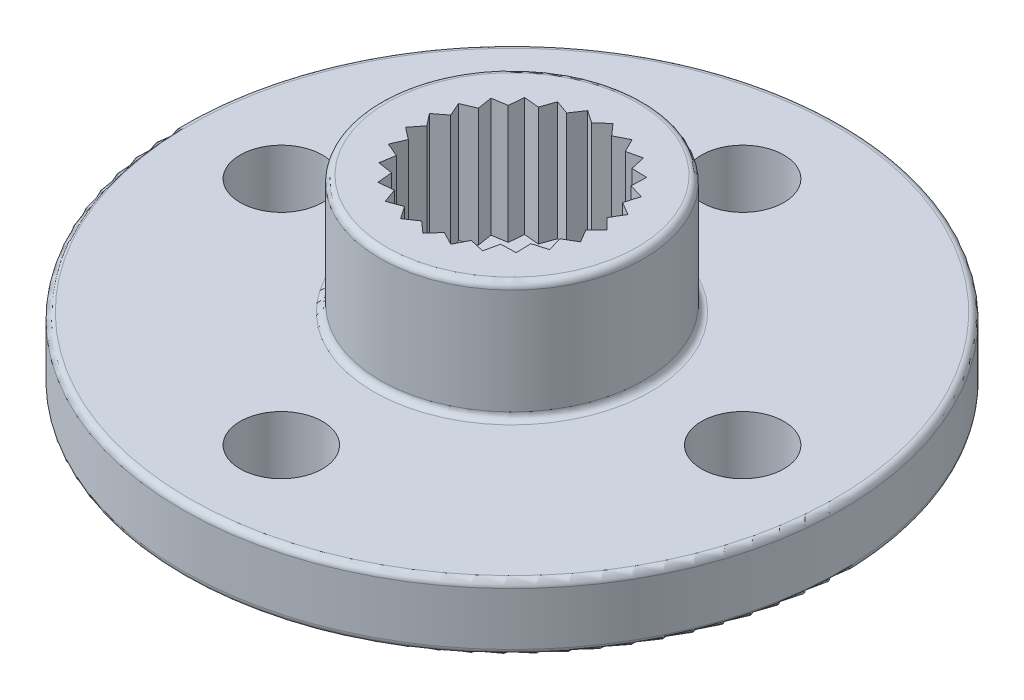
from build123d import *

# Parameters (mm, degrees)
SKETCH2_R             = 10
BOSS_EXTRUDE1_DEPTH   = 2
SKETCH3_R             = 4
BOSS_EXTRUDE2_DEPTH   = 3.6
M3X0_5_TAPPED_HOLE1_D = 2.5
SKETCH6_R             = 2.585
CUT_EXTRUDE1_DEPTH    = 3.6
SKETCH7_R             = 1.5
CUT_EXTRUDE2_DEPTH    = 3
FILLET1_R             = 0.2
CUT_EXTRUDE6_DEPTH    = 3.6
CIRPATTERN1_COUNT     = 25
CHAMFER1_SIZE         = 0.5


with BuildPart() as part:
    # Sketch2 → Boss-Extrude1 (new body)
    with BuildSketch(Plane(origin=(0, 0, 0), x_dir=(1, 0, 0), z_dir=(0, 1, 0))):
        Circle(SKETCH2_R)
    extrude(amount=BOSS_EXTRUDE1_DEPTH)

    # Sketch3 → Boss-Extrude2 (add)
    with BuildSketch(Plane(origin=(0, 2, 0), x_dir=(1, 0, 0), z_dir=(0, 1, 0))):
        Circle(SKETCH3_R)
    extrude(amount=BOSS_EXTRUDE2_DEPTH)

    # M3x0.5 Tapped Hole1 (through all)
    with Locations(Plane(origin=(0, 2, 0), x_dir=(1, 0, 0), z_dir=(0, 1, 0))):
        with Locations((0, 7), (-7, 0), (0, -7), (7, 0)):
            Hole(M3X0_5_TAPPED_HOLE1_D / 2)

    # Sketch6 → Cut-Extrude1 (cut)
    with BuildSketch(Plane(origin=(0, 5.6, 0), x_dir=(1, 0, 0), z_dir=(0, 1, 0))):
        Circle(SKETCH6_R)
    extrude(amount=-CUT_EXTRUDE1_DEPTH, mode=Mode.SUBTRACT)

    # Sketch7 → Cut-Extrude2 (cut, through all)
    with BuildSketch(Plane(origin=(0, 2, 0), x_dir=(1, 0, 0), z_dir=(0, 1, 0))):
        Circle(SKETCH7_R)
    extrude(amount=-CUT_EXTRUDE2_DEPTH, mode=Mode.SUBTRACT)

    # Fillet1
    fillet1_edges = [part.edges().sort_by_distance(p)[0] for p in [
        (-10, 0, 0),
        (-10, 2, 0),
        (-4, 2, 0),
        (-4, 5.6, 0),
    ]]
    fillet(fillet1_edges, radius=FILLET1_R)

    # Sketch8 → Cut-Extrude6 (cut)
    with BuildSketch(Plane(origin=(0, 5.6, 0), x_dir=(1, 0, 0), z_dir=(0, 1, 0))):
        with BuildLine():
            Line((2.564616503, 0.323986409), (2.89, 0))
            Line((2.89, 0), (2.564616503, -0.323986409))
            ThreePointArc((2.564616503, -0.323986409), (2.585, 0), (2.564616503, 0.323986409))
        make_face()
    cut_extrude6 = extrude(amount=-CUT_EXTRUDE6_DEPTH, mode=Mode.SUBTRACT)

    # CirPattern1: Cut-Extrude6 ×25 about axis
    cirpattern1_axis = Axis((0, 0, 0), (0, 1, 0))
    for i in range(1, CIRPATTERN1_COUNT):
        add(cut_extrude6.rotate(cirpattern1_axis, i * 360 / CIRPATTERN1_COUNT), mode=Mode.SUBTRACT)

    # Chamfer1
    chamfer1_edges = [part.edges().sort_by_distance(p)[0] for p in [
        (-1.5, 0, 0),
    ]]
    chamfer(chamfer1_edges, length=CHAMFER1_SIZE)


solid = part.part
